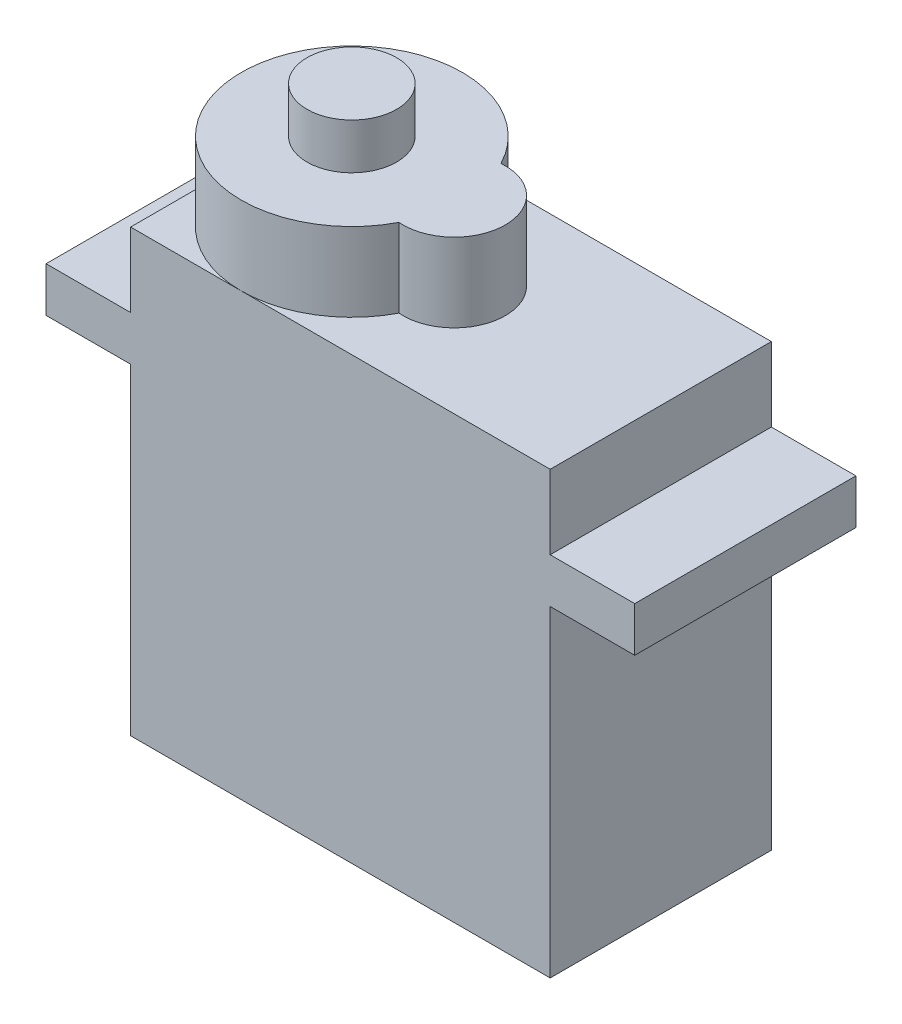
from build123d import *

# Parameters (mm, degrees)
SKETCH1_W           = 22.95
SKETCH1_H           = 12.1
BOSS_EXTRUDE1_DEPTH = 24.1
BOSS_EXTRUDE2_DEPTH = 4.3
SKETCH3_W           = 4.625
SKETCH3_H           = 12.1
BOSS_EXTRUDE3_DEPTH = 2.45
SKETCH4_R           = 2.45
BOSS_EXTRUDE4_DEPTH = 2.5
SKETCH5_R           = 0.65
BOSS_EXTRUDE7_DEPTH = 3.9


with BuildPart() as part:
    # Sketch1 → Boss-Extrude1 (new body)
    with BuildSketch(Plane(origin=(0, 0, 0), x_dir=(1, 0, 0), z_dir=(0, 1, 0))):
        Rectangle(SKETCH1_W, SKETCH1_H)
    extrude(amount=BOSS_EXTRUDE1_DEPTH)

    # Sketch2 → Boss-Extrude2 (add)
    with BuildSketch(Plane(origin=(0, 24.1, 0), x_dir=(1, 0, 0), z_dir=(0, 1, 0))):
        with BuildLine():
            ThreePointArc((-0.056919643, 2.790378698), (-11.475, 0), (-0.056919643, -2.790378698))
            ThreePointArc((-0.056919643, -2.790378698), (2.975, 0), (-0.056919643, 2.790378698))
        make_face()
    extrude(amount=BOSS_EXTRUDE2_DEPTH)

    # Sketch3 → Boss-Extrude3 (add)
    with BuildSketch(Plane(origin=(0, 20.05, 0), x_dir=(1, 0, 0), z_dir=(0, 1, 0))):
        with Locations((-13.7875, 0)):
            Rectangle(SKETCH3_W, SKETCH3_H)
        with Locations((13.7875, 0)):
            Rectangle(SKETCH3_W, SKETCH3_H)
    extrude(amount=-BOSS_EXTRUDE3_DEPTH)

    # Sketch4 → Boss-Extrude4 (add)
    with BuildSketch(Plane(origin=(0, 28.4, 0), x_dir=(1, 0, 0), z_dir=(0, 1, 0))):
        with Locations((-5.425, 0)):
            Circle(SKETCH4_R)
    extrude(amount=BOSS_EXTRUDE4_DEPTH)

    # Sketch5 → Boss-Extrude7 (add)
    with BuildSketch(Plane.ZY.offset(11.475)):
        with Locations((0, 4)):
            Circle(SKETCH5_R)
        with Locations((1.34, 4)):
            Circle(SKETCH5_R)
        with Locations((-1.34, 4)):
            Circle(SKETCH5_R)
    extrude(amount=BOSS_EXTRUDE7_DEPTH)


solid = part.part
